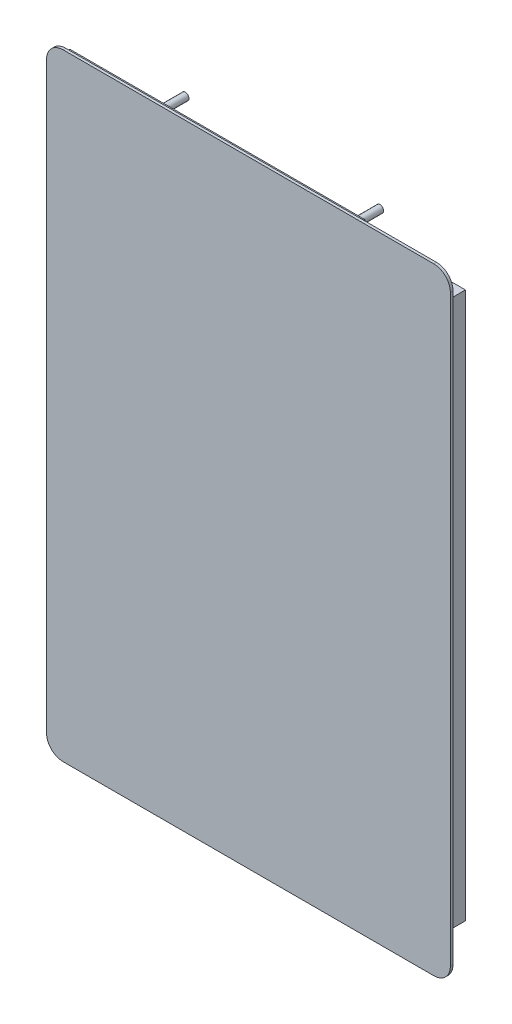
from build123d import *

# Parameters (mm, degrees)
BOSS_EXTRUDE1_DEPTH = 1.1
SKETCH3_W           = 122
SKETCH3_H           = 254
BOSS_EXTRUDE2_DEPTH = 1
SKETCH4_W           = 32
SKETCH4_H           = 226
BOSS_EXTRUDE3_DEPTH = 10.6
SKETCH5_R           = 1.5
BOSS_EXTRUDE4_DEPTH = 30.1


with BuildPart() as part:
    # Sketch2 → Boss-Extrude1 (new body)
    with BuildSketch(Plane.XY):
        with BuildLine():
            Line((-76.67, -127.5), (76.67, -127.5))
            ThreePointArc((76.67, -127.5), (81.499539316, -125.499539316), (83.5, -120.67))
            Line((83.5, -120.67), (83.5, 120.67))
            ThreePointArc((83.5, 120.67), (81.499539316, 125.499539316), (76.67, 127.5))
            Line((76.67, 127.5), (-76.67, 127.5))
            ThreePointArc((-76.67, 127.5), (-81.499539316, 125.499539316), (-83.5, 120.67))
            Line((-83.5, 120.67), (-83.5, -120.67))
            ThreePointArc((-83.5, -120.67), (-81.499539316, -125.499539316), (-76.67, -127.5))
        make_face()
    extrude(amount=BOSS_EXTRUDE1_DEPTH)

    # Sketch3 → Boss-Extrude2 (add)
    with BuildSketch(Plane(origin=(0, 0, 0), x_dir=(-1, 0, 0), z_dir=(0, 0, -1))):
        with Locations((14.96, 0)):
            Rectangle(SKETCH3_W, SKETCH3_H)
    extrude(amount=BOSS_EXTRUDE2_DEPTH)

    # Sketch4 → Boss-Extrude3 (add)
    with BuildSketch(Plane(origin=(0, 0, 0), x_dir=(-1, 0, 0), z_dir=(0, 0, -1))):
        with Locations((-62.04, 0)):
            Rectangle(SKETCH4_W, SKETCH4_H)
    extrude(amount=BOSS_EXTRUDE3_DEPTH)

    # Sketch5 → Boss-Extrude4 (add)
    with BuildSketch(Plane(origin=(0, 0, 0), x_dir=(-1, 0, 0), z_dir=(0, 0, -1))):
        with Locations((-23.21, -104.9)):
            Circle(SKETCH5_R)
        with Locations((57.3, -104.9)):
            Circle(SKETCH5_R)
        with Locations((57.3, 104.9)):
            Circle(SKETCH5_R)
        with Locations((-23.21, 104.9)):
            Circle(SKETCH5_R)
    extrude(amount=BOSS_EXTRUDE4_DEPTH)


solid = part.part
